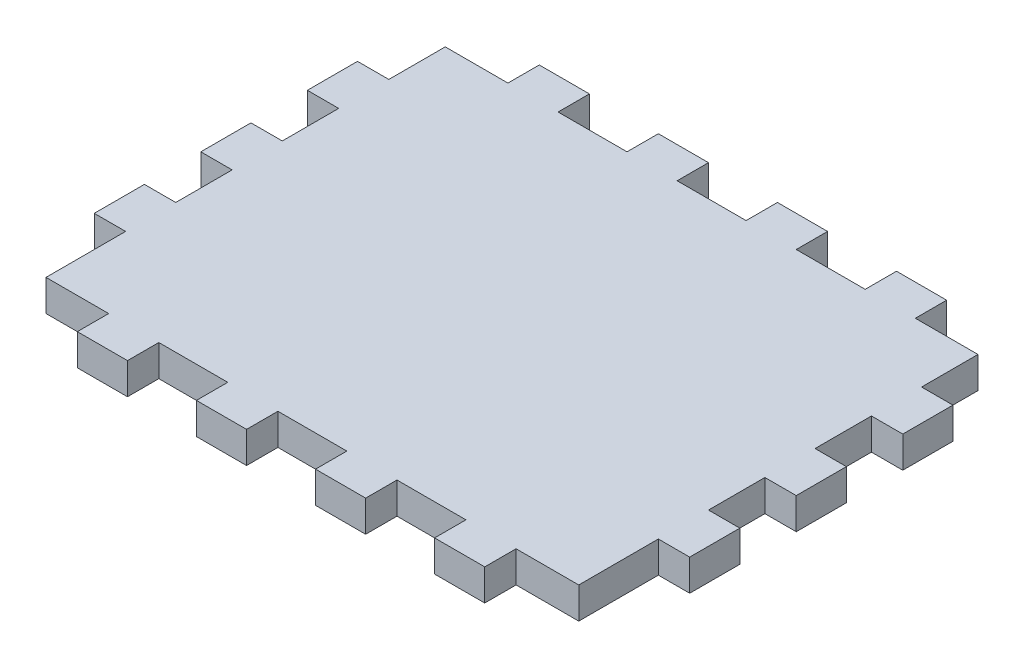
from build123d import *

# Parameters (mm, degrees)
BOSS_EXTRUDE1_DEPTH = 5


with BuildPart() as part:
    # Sketch1 → Boss-Extrude1 (new body)
    with BuildSketch(Plane(origin=(0, 0, 0), x_dir=(1, 0, 0), z_dir=(0, 1, 0))):
        Polygon((-44.257261197, 24.285098332), (-34.257261197, 24.285098332), (-34.257261197, 29.285098332), (-26.257261197, 29.285098332), (-26.257261197, 24.285098332), (-15.257261197, 24.285098332), (-15.257261197, 29.285098332), (-7.257261197, 29.285098332), (-7.257261197, 24.285098332), (3.742738803, 24.285098332), (3.742738803, 29.285098332), (11.742738803, 29.285098332), (11.742738803, 24.285098332), (22.742738803, 24.285098332), (22.742738803, 29.285098332), (30.742738803, 29.285098332), (30.742738803, 24.285098332), (40.742738803, 24.285098332), (40.742738803, 15.285098332), (45.742738803, 15.285098332), (45.742738803, 7.285098332), (40.742738803, 7.285098332), (40.742738803, -1.714901668), (45.742738803, -1.714901668), (45.742738803, -9.714901668), (40.742738803, -9.714901668), (40.742738803, -18.714901668), (45.742738803, -18.714901668), (45.742738803, -26.714901668), (40.742738803, -26.714901668), (40.742738803, -39.414901668), (30.742738803, -39.414901668), (30.742738803, -44.414901668), (22.742738803, -44.414901668), (22.742738803, -39.414901668), (11.742738803, -39.414901668), (11.742738803, -44.414901668), (3.742738803, -44.414901668), (3.742738803, -39.414901668), (-7.257261197, -39.414901668), (-7.257261197, -44.414901668), (-15.257261197, -44.414901668), (-15.257261197, -39.414901668), (-26.257261197, -39.414901668), (-26.257261197, -44.414901668), (-34.257261197, -44.414901668), (-34.257261197, -39.414901668), (-44.257261197, -39.414901668), (-44.257261197, -26.714901668), (-49.257261197, -26.714901668), (-49.257261197, -18.714901668), (-44.257261197, -18.714901668), (-44.257261197, -9.714901668), (-49.257261197, -9.714901668), (-49.257261197, -1.714901668), (-44.257261197, -1.714901668), (-44.257261197, 7.285098332), (-49.257261197, 7.285098332), (-49.257261197, 15.285098332), (-44.257261197, 15.285098332), align=None)
    extrude(amount=BOSS_EXTRUDE1_DEPTH)


solid = part.part
